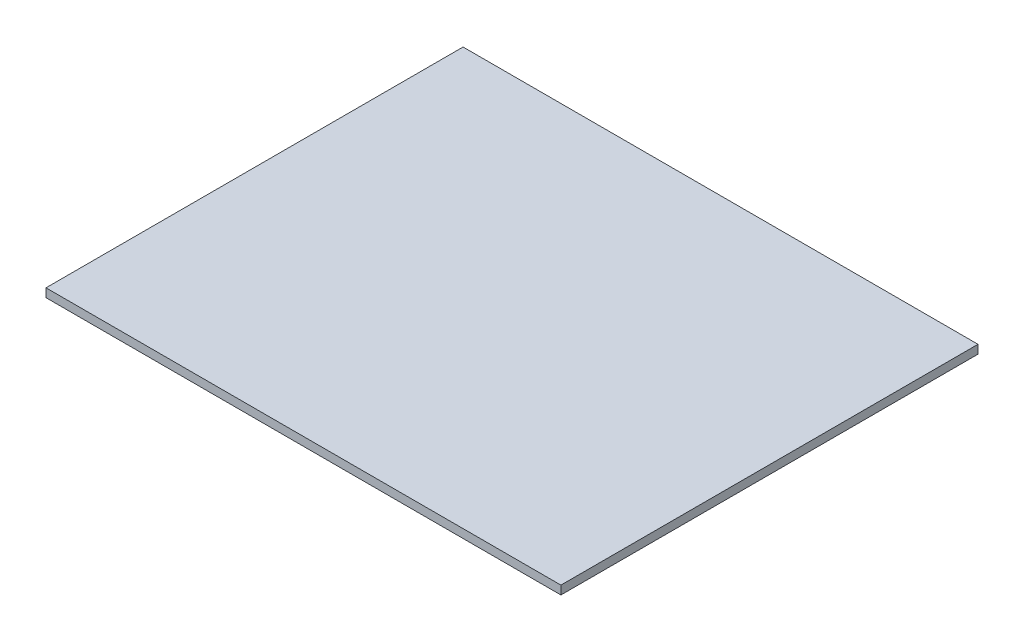
from build123d import *

# Parameters (mm, degrees)
SKETCH1_W           = 600
SKETCH1_H           = 486
BOSS_EXTRUDE1_DEPTH = 10


with BuildPart() as part:
    # Sketch1 → Boss-Extrude1 (new body)
    with BuildSketch(Plane(origin=(0, 0, 0), x_dir=(1, 0, 0), z_dir=(0, 1, 0))):
        with Locations((300, 243)):
            Rectangle(SKETCH1_W, SKETCH1_H)
    extrude(amount=BOSS_EXTRUDE1_DEPTH)


solid = part.part
